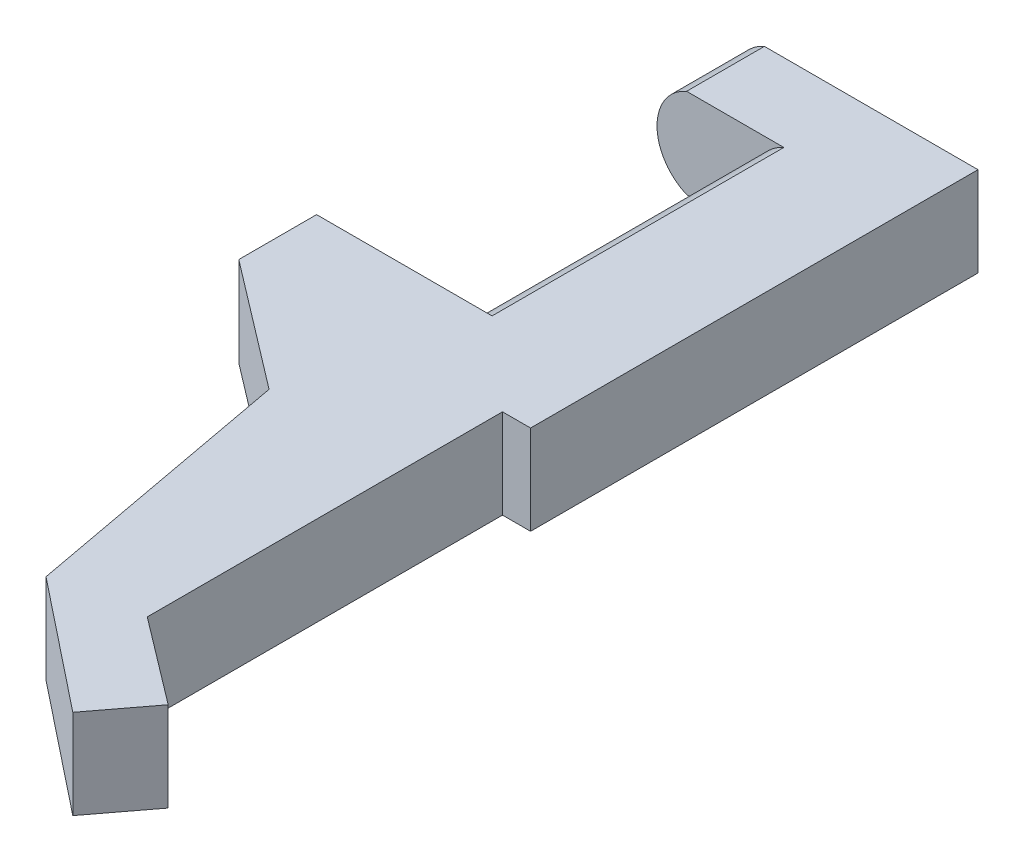
from build123d import *

# Parameters (mm, degrees)
EXTRUDE_1_DEPTH     = 15
EXTRUDE_2_DEPTH     = 4
SKETCH_3_W          = 15
SKETCH_3_H          = 5
EXTRUDE_3_DEPTH     = 4
EXTRUDE_4_DEPTH     = 2.5
SKETCH_5_W          = 22.090290278
SKETCH_5_H          = 0.2
CUT_EXTRUDE_1_DEPTH = 48.422190659


with BuildPart() as part:
    # 草图1 → 凸台-拉伸1 (new body)
    with BuildSketch(Plane.XY):
        with BuildLine():
            Line((539.301234579, 412.744075086), (539.301234579, 407.744075086))
            Line((539.301234579, 407.744075086), (534.301234579, 407.744075086))
            ThreePointArc((534.301234579, 407.744075086), (531.801234579, 410.244075086), (534.301234579, 412.744075086))
            Line((534.301234579, 412.744075086), (539.301234579, 412.744075086))
        make_face()
    extrude(amount=-EXTRUDE_1_DEPTH)

    # 草图2 → 凸台-拉伸2 (add)
    with BuildSketch(Plane(origin=(0, 0, -15), x_dir=(-1, 0, 0), z_dir=(0, 0, -1))):
        with BuildLine():
            Line((-539.301234579, 412.744075086), (-529.301234579, 412.744075086))
            ThreePointArc((-529.301234579, 412.744075086), (-526.801234579, 410.244075086), (-529.301234579, 407.744075086))
            Line((-529.301234579, 407.744075086), (-539.301234579, 407.744075086))
            Line((-539.301234579, 407.744075086), (-539.301234579, 412.744075086))
        make_face()
    extrude(amount=EXTRUDE_2_DEPTH)

    # 草图3 → 凸台-拉伸3 (add)
    with BuildSketch(Plane.XY):
        with Locations((531.801234579, 410.244075086)):
            Rectangle(SKETCH_3_W, SKETCH_3_H)
    extrude(amount=EXTRUDE_3_DEPTH)

    # 草图4 → 凸台-拉伸4 (add, symmetric)
    with BuildSketch(Plane(origin=(0, 410.244075086, 0), x_dir=(-1, 0, 0), z_dir=(0, -1, 0))):
        Polygon((-524.301234579, -4), (-537.858436246, -4), (-537.858436246, -22.261188512), (-542.306519396, -25.63298203), (-540.192207397, -28.422190659), (-533.467268804, -23.075095635), (-530.858436246, -9), align=None)
    extrude(amount=EXTRUDE_4_DEPTH, both=True)

    # 草图5 → 切除-拉伸1 (cut, through all)
    with BuildSketch(Plane(origin=(0, 0, -19), x_dir=(-1, 0, 0), z_dir=(0, 0, -1))):
        with Locations((-533.503634439, 412.644075086)):
            Rectangle(SKETCH_5_W, SKETCH_5_H)
        with Locations((-533.503634439, 407.844075086)):
            Rectangle(SKETCH_5_W, SKETCH_5_H)
    extrude(amount=-CUT_EXTRUDE_1_DEPTH, mode=Mode.SUBTRACT)


solid = part.part
